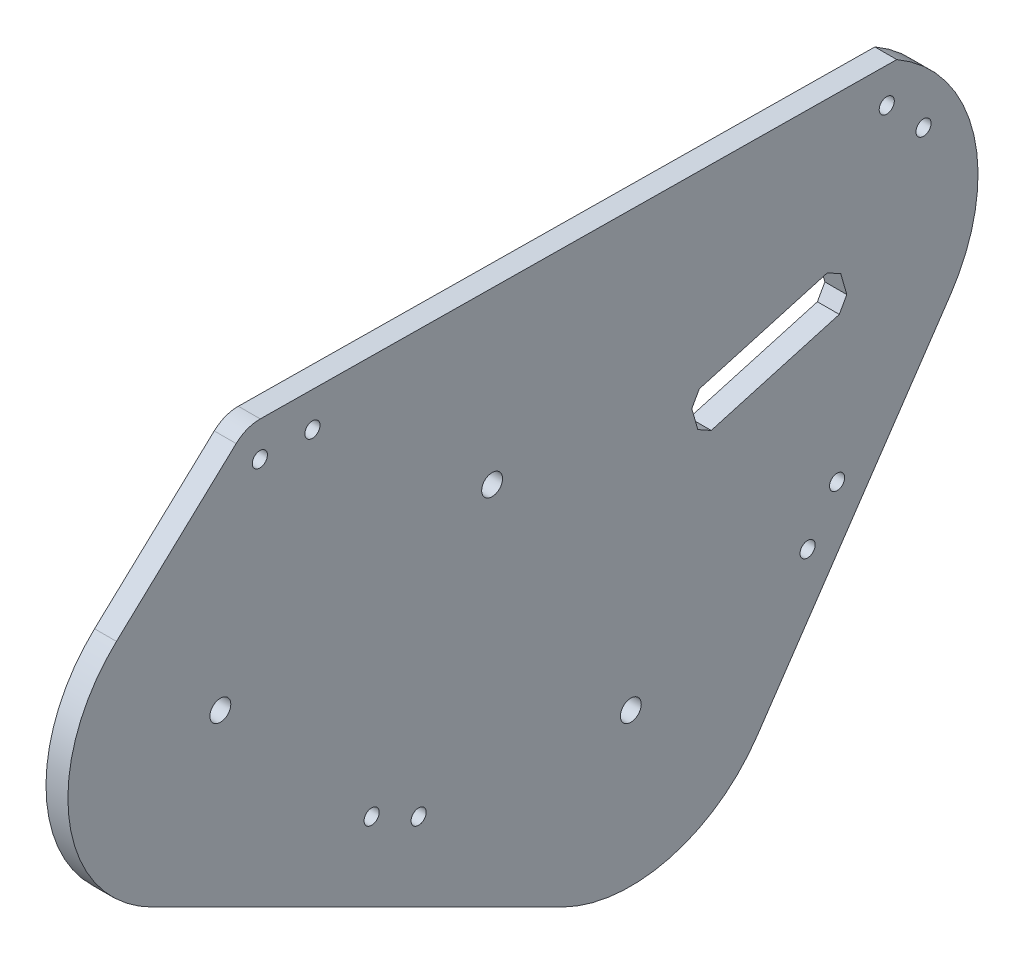
from build123d import *

# Parameters (mm, degrees)
SKETCH4_R           = 1.7272
BOSS_EXTRUDE1_DEPTH = 5
SKETCH6_R           = 2.38125
CUT_EXTRUDE3_DEPTH  = 563.967871169


with BuildPart() as part:
    # Sketch4 → Boss-Extrude1 (new body)
    with BuildSketch(Plane(origin=(0, 0, 0), x_dir=(0, 0, -1), z_dir=(1, 0, 0))):
        with BuildLine():
            Line((-510.682190934, 38.038925927), (-365.377526066, 36.419992053))
            ThreePointArc((-365.377526066, 36.419992053), (-347.780080684, 12.728604031), (-353.180701811, -16.284931462))
            Line((-353.180701811, -16.284931462), (-397.273694981, -81.364150349))
            ThreePointArc((-397.273694981, -81.364150349), (-417.278222711, -95.513055214), (-441.64877195, -92.973573308))
            Line((-441.64877195, -92.973573308), (-535.34498696, -46.137884003))
            ThreePointArc((-535.34498696, -46.137884003), (-554.231450435, -19.972248852), (-543.504008498, 10.46228671))
            Line((-543.504008498, 10.46228671), (-516.180391889, 35.910386439))
            ThreePointArc((-516.180391889, 35.910386439), (-513.636251412, 37.504085531), (-510.682190934, 38.038925927))
        make_face()
        with Locations((-485.252549027, -53.289868312)):
            Circle(SKETCH4_R, mode=Mode.SUBTRACT)
        with Locations((-474.518853752, -58.65529334)):
            Circle(SKETCH4_R, mode=Mode.SUBTRACT)
        with Locations((-510.7706223, 30.101918548)):
            Circle(SKETCH4_R, mode=Mode.SUBTRACT)
        with Locations((-498.771367049, 29.968227033)):
            Circle(SKETCH4_R, mode=Mode.SUBTRACT)
        with Locations((-367.666774725, 28.507505411)):
            Circle(SKETCH4_R, mode=Mode.SUBTRACT)
        with Locations((-359.276554144, 19.928216477)):
            Circle(SKETCH4_R, mode=Mode.SUBTRACT)
        with Locations((-385.737171654, -50.185658721)):
            Circle(SKETCH4_R, mode=Mode.SUBTRACT)
        with Locations((-379.006254083, -40.251135649)):
            Circle(SKETCH4_R, mode=Mode.SUBTRACT)
    extrude(amount=-BOSS_EXTRUDE1_DEPTH)

    # Sketch6 → Cut-Extrude3 (cut, through all)
    with BuildSketch(Plane(origin=(0, 0, 0), x_dir=(0, 0, -1), z_dir=(1, 0, 0))):
        with Locations((-519.783421193, -15.006500358)):
            Circle(SKETCH6_R)
        with Locations((-457.75455229, -1.41718755)):
            Circle(SKETCH6_R)
        with Locations((-426.087206182, -61.842189663)):
            Circle(SKETCH6_R)
        Polygon((-410.800244566, -14.012433181), (-407.736158639, -15.718577512), (-378.497536933, -7.395218158), (-376.791392602, -4.331132231), (-378.160423785, 0.478053958), (-381.224509713, 2.184198289), (-410.463131418, -6.139161065), (-412.169275749, -9.203246993), align=None)
    extrude(amount=-CUT_EXTRUDE3_DEPTH, mode=Mode.SUBTRACT)


solid = part.part
